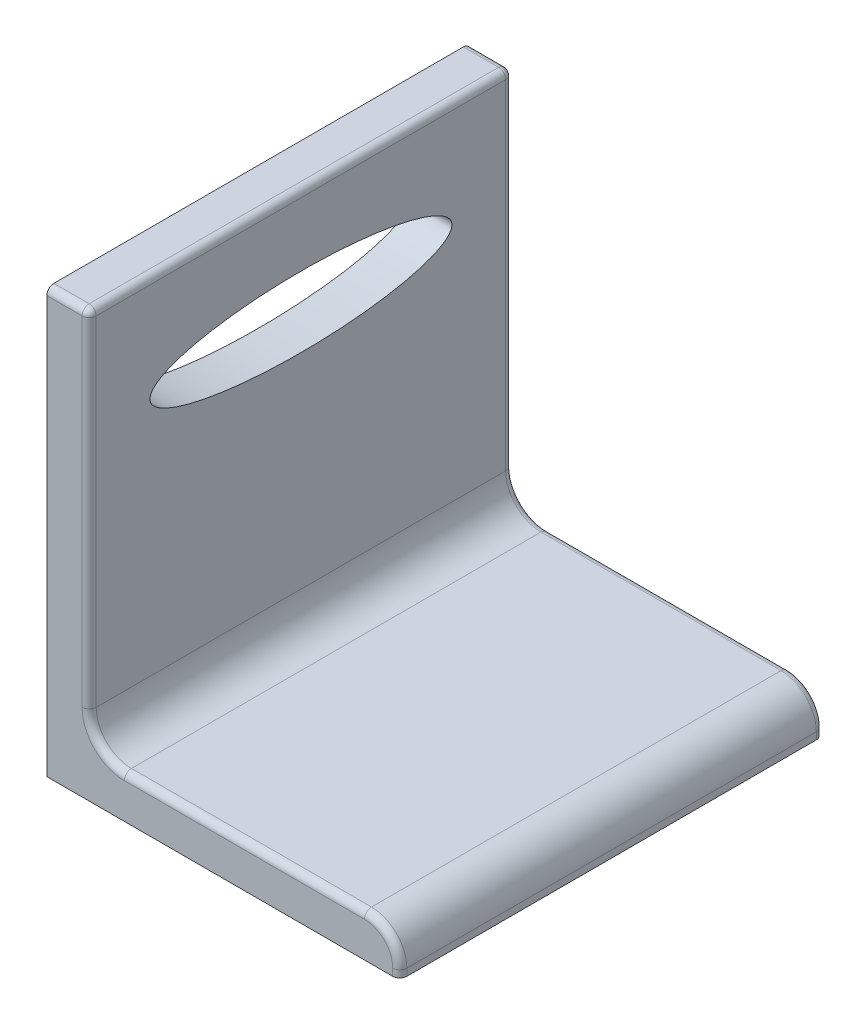
from build123d import *

# Parameters (mm, degrees)
ESQUISSE1_W             = 12
ESQUISSE1_H             = 108
ESQUISSE1_W_2           = 100
ESQUISSE1_H_2           = 12
BOSS_EXTRU_1_DEPTH      = 120
ESQUISSE2_RX            = 42.771597922
ESQUISSE2_RY            = 10
ENL_V_MAT_EXTRU_1_DEPTH = 12
CONG_1_R                = 10
CONG_2_R                = 10
CONG_3_R                = 2
CONG_4_R                = 2
CONG_5_R                = 2


with BuildPart() as part:
    # Esquisse1 → Boss.-Extru.1 (new body)
    with BuildSketch(Plane.XY):
        with Locations((6, 66)):
            Rectangle(ESQUISSE1_W, ESQUISSE1_H)
        with Locations((50, 6)):
            Rectangle(ESQUISSE1_W_2, ESQUISSE1_H_2)
    extrude(amount=-BOSS_EXTRU_1_DEPTH)

    # Esquisse2 → Enlèv. mat.-Extru.1 (cut)
    with BuildSketch(Plane.ZY):
        with Locations(Location((-60, 90), (0, 0, 0))):
            Ellipse(ESQUISSE2_RX, ESQUISSE2_RY)
    extrude(amount=-ENL_V_MAT_EXTRU_1_DEPTH, mode=Mode.SUBTRACT)

    # Congé1
    cong_1_edges = [part.edges().sort_by_distance(p)[0] for p in [
        (100, 12, -60),
    ]]
    fillet(cong_1_edges, radius=CONG_1_R)

    # Congé2
    cong_2_edges = [part.edges().sort_by_distance(p)[0] for p in [
        (12, 12, -60),
    ]]
    fillet(cong_2_edges, radius=CONG_2_R)

    # Congé3
    cong_3_edges = [part.edges().sort_by_distance(p)[0] for p in [
        (100, 1, 0),
        (97.071067812, 9.071067812, 0),
        (56, 12, 0),
        (12, 71, 0),
        (14.928932188, 14.928932188, 0),
    ]]
    fillet(cong_3_edges, radius=CONG_3_R)

    # Congé4
    cong_4_edges = [part.edges().sort_by_distance(p)[0] for p in [
        (100, 1, -120),
        (97.071067812, 9.071067812, -120),
        (56, 12, -120),
        (12, 71, -120),
        (14.928932188, 14.928932188, -120),
    ]]
    fillet(cong_4_edges, radius=CONG_4_R)

    # Congé5
    cong_5_edges = [part.edges().sort_by_distance(p)[0] for p in [
        (5, 120, 0),
        (5, 120, -120),
        (11.414213562, 120, -0.585786438),
        (12, 120, -60),
        (11.414213562, 120, -119.414213562),
    ]]
    fillet(cong_5_edges, radius=CONG_5_R)


solid = part.part
